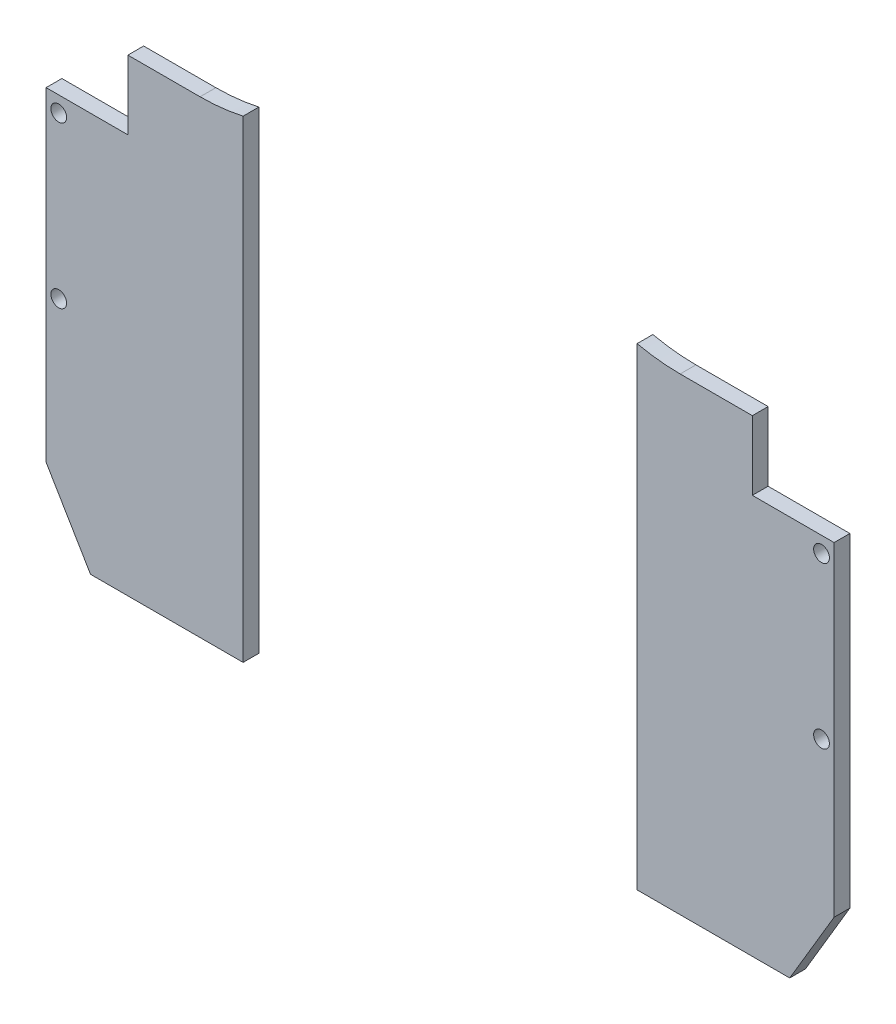
from build123d import *

# Parameters (mm, degrees)
SKETCH1_W           = 250
SKETCH1_H           = 221.085663757
SKETCH1_R           = 2.5
BOSS_EXTRUDE1_DEPTH = 5
SKETCH6_R           = 62.5
CUT_EXTRUDE4_DEPTH  = 6
SKETCH7_W           = 125
SKETCH7_H           = 298.698107089
CUT_EXTRUDE5_DEPTH  = 5


with BuildPart() as part:
    # Sketch1 → Boss-Extrude1 (new body)
    with BuildSketch(Plane.XY):
        with Locations((-3368.041949546, -177.462013972)):
            Rectangle(SKETCH1_W, SKETCH1_H)
        with Locations((-3489.041949546, -217.319182093)):
            Circle(SKETCH1_R, mode=Mode.SUBTRACT)
        with Locations((-3489.041949546, -166.319182093)):
            Circle(SKETCH1_R, mode=Mode.SUBTRACT)
        with Locations((-3247.041949546, -166.319182093)):
            Circle(SKETCH1_R, mode=Mode.SUBTRACT)
        with Locations((-3247.041949546, -217.319182093)):
            Circle(SKETCH1_R, mode=Mode.SUBTRACT)
    extrude(amount=BOSS_EXTRUDE1_DEPTH)

    # Sketch6 → Cut-Extrude4 (cut, through all)
    with BuildSketch(Plane.XY):
        with Locations((-3368.041949546, -300.417289182)):
            Circle(SKETCH6_R)
        Polygon((-3503.457885375, -270.451546314), (-3493.041949546, -264.270843991), (-3478.958452604, -288.00484585), (-3489.374388434, -294.185548172), align=None)
        with BuildLine():
            Line((-3493.041949546, -161.319182093), (-3493.041949546, -66.919182093))
            Line((-3493.041949546, -66.919182093), (-3382.503777097, -66.919182093))
            ThreePointArc((-3382.503777097, -66.919182093), (-3396.600008581, -117.423811459), (-3444.198590493, -139.419182093))
            Line((-3444.198590493, -139.419182093), (-3467.101949546, -139.419182093))
            Line((-3467.101949546, -139.419182093), (-3467.101949546, -161.319182093))
            Line((-3467.101949546, -161.319182093), (-3493.041949546, -161.319182093))
        make_face()
        Polygon((-3246.709510658, -294.185548172), (-3257.125446487, -288.00484585), (-3243.041949546, -264.270843991), (-3232.626013716, -270.451546314), align=None)
        with BuildLine():
            Line((-3268.981949546, -139.419182093), (-3291.885308598, -139.419182093))
            ThreePointArc((-3291.885308598, -139.419182093), (-3339.48389051, -117.423811459), (-3353.580121995, -66.919182093))
            Line((-3353.580121995, -66.919182093), (-3243.041949546, -66.919182093))
            Line((-3243.041949546, -66.919182093), (-3243.041949546, -161.319182093))
            Line((-3243.041949546, -161.319182093), (-3268.981949546, -161.319182093))
            Line((-3268.981949546, -161.319182093), (-3268.981949546, -139.419182093))
        make_face()
    extrude(amount=CUT_EXTRUDE4_DEPTH, mode=Mode.SUBTRACT)

    # Sketch7 → Cut-Extrude5 (cut)
    with BuildSketch(Plane.XY.offset(5)):
        with Locations((-3368.041949546, -216.268235638)):
            Rectangle(SKETCH7_W, SKETCH7_H)
    extrude(amount=-CUT_EXTRUDE5_DEPTH, mode=Mode.SUBTRACT)


solid = part.part
